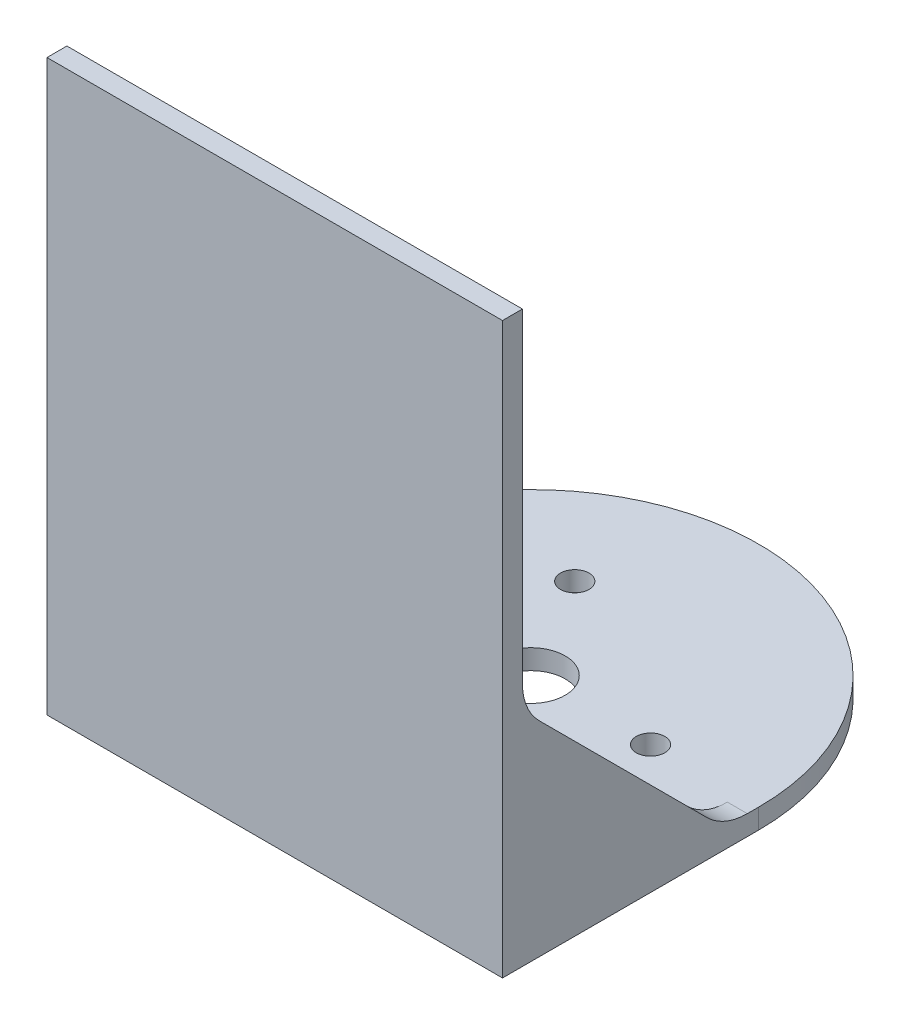
from build123d import *

# Parameters (mm, degrees)
SKETCH1_R            = 2.5
SKETCH1_R_2          = 6
BOSS_EXTRUDE1_DEPTH  = 3.5
SKETCH1_3_W          = 80
SKETCH1_3_H          = 3.5
BOSS_EXTRUDE2_DEPTH  = 100
BOSS_EXTRUDE3_DEPTH  = 3.5
FILLET1_R            = 10
FILLET1_OF_MIRROR1_R = 10


with BuildPart() as part:
    # Sketch1 → Boss-Extrude1 (new body)
    with BuildSketch(Plane(origin=(0, 0, 0), x_dir=(1, 0, 0), z_dir=(0, 1, 0))):
        with BuildLine():
            ThreePointArc((40, 0), (0, 40), (-40, 0))
            Line((-40, 0), (-40, -41.5))
            Line((-40, -41.5), (40, -41.5))
            Line((40, -41.5), (40, 0))
        make_face()
        with Locations((21, 0)):
            Circle(SKETCH1_R, mode=Mode.SUBTRACT)
        with Locations((-10.5, 18.186533479)):
            Circle(SKETCH1_R, mode=Mode.SUBTRACT)
        with Locations((-10.5, -18.186533479)):
            Circle(SKETCH1_R, mode=Mode.SUBTRACT)
        Circle(SKETCH1_R_2, mode=Mode.SUBTRACT)
    extrude(amount=BOSS_EXTRUDE1_DEPTH)

    # Sketch1_3 → Boss-Extrude2 (add)
    with BuildSketch(Plane(origin=(0, 0, 0), x_dir=(1, 0, 0), z_dir=(0, 1, 0))):
        with Locations((0, -43.25)):
            Rectangle(SKETCH1_3_W, SKETCH1_3_H)
    extrude(amount=BOSS_EXTRUDE2_DEPTH)

    # Sketch5 → Boss-Extrude3 (add)
    with BuildSketch(Plane.ZY.offset(40)):
        Polygon((6.144660941, 3.5), (41.5, 38.855339059), (41.5, 3.5), align=None)
    boss_extrude3 = extrude(amount=-BOSS_EXTRUDE3_DEPTH)

    # Fillet1
    fillet1_edges = [part.edges().sort_by_distance(p)[0] for p in [
        (-38.25, 3.5, 6.144660941),
        (-38.25, 38.855339059, 41.5),
    ]]
    fillet(fillet1_edges, radius=FILLET1_R)

    # Mirror1: Boss-Extrude3 across plane
    add(boss_extrude3.mirror(Plane(origin=(0, 0, 0), x_dir=(0, 0, 1), z_dir=(1, 0, 0))))

    # Fillet1 of Mirror1
    fillet1_of_mirror1_edges = [part.edges().sort_by_distance(p)[0] for p in [
        (38.25, 3.5, 6.144660941),
        (38.25, 38.855339059, 41.5),
    ]]
    fillet(fillet1_of_mirror1_edges, radius=FILLET1_OF_MIRROR1_R)


solid = part.part
